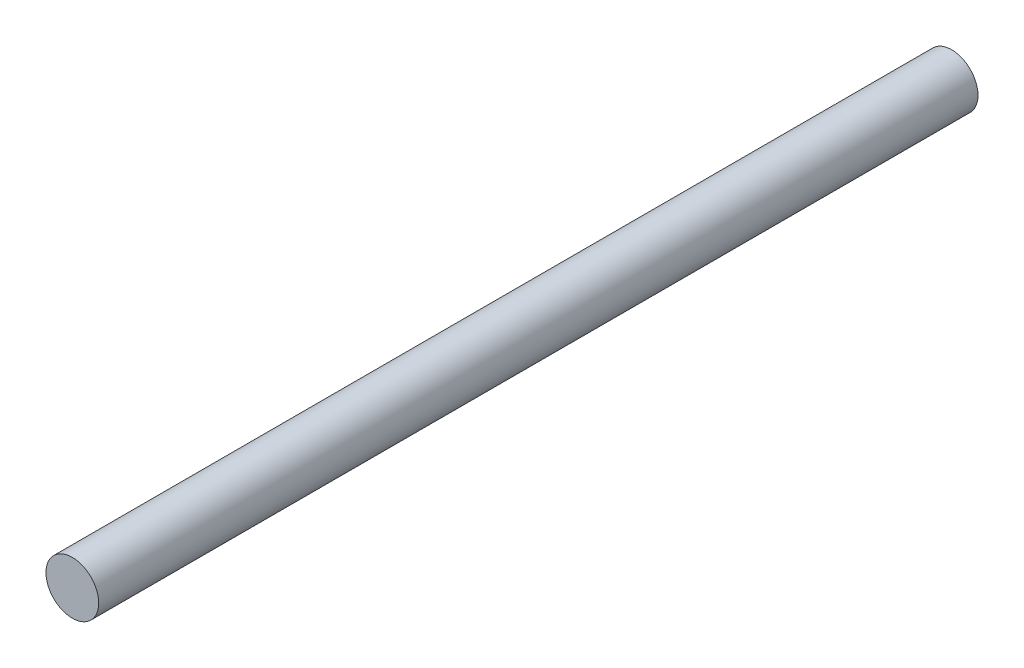
from build123d import *

# Parameters (mm, degrees)
SKETCH1_R           = 15
BOSS_EXTRUDE1_DEPTH = 500


with BuildPart() as part:
    # Sketch1 → Boss-Extrude1 (new body)
    with BuildSketch(Plane.XY):
        Circle(SKETCH1_R)
    extrude(amount=BOSS_EXTRUDE1_DEPTH)


solid = part.part
